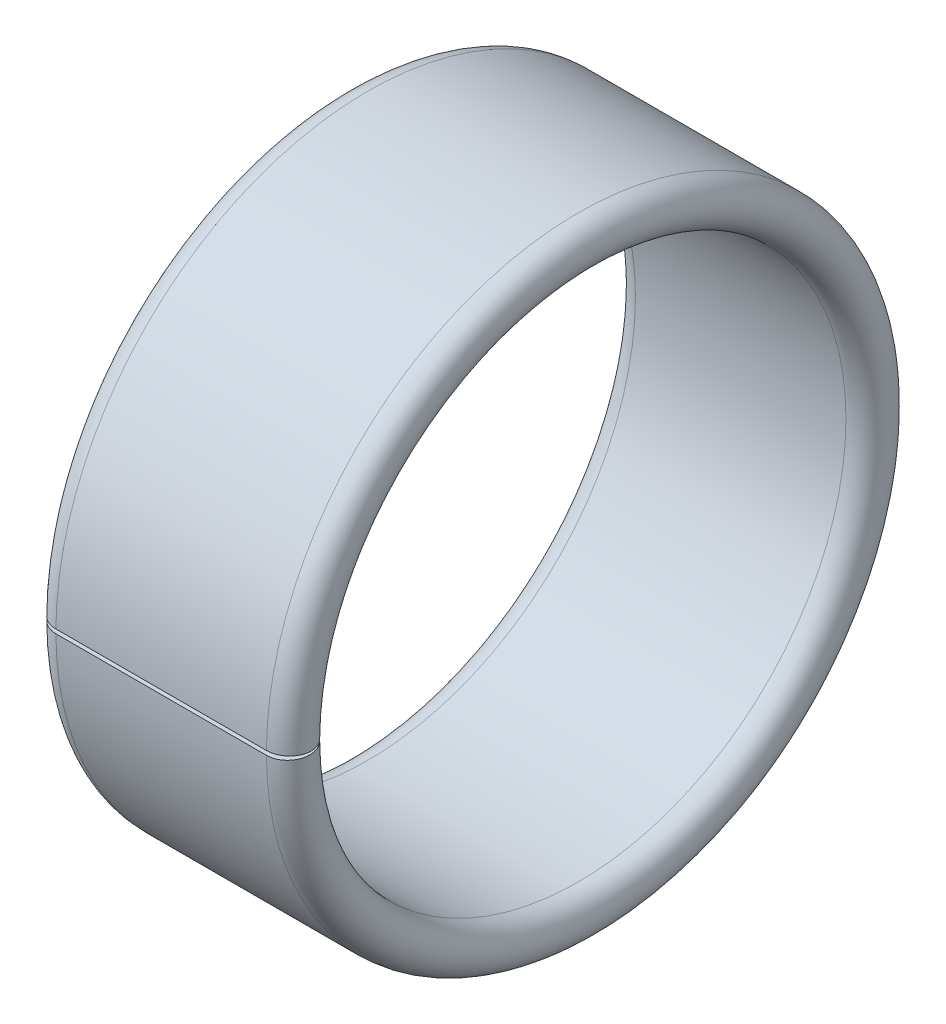
from build123d import *

# Parameters (mm, degrees)
CUT_EXTRUDE1_DEPTH = 4.9


with BuildPart() as part:
    # Sketch1 → Revolve1 (revolve)
    with BuildSketch(Plane.XY):
        with BuildLine():
            Line((0.425, 5.15), (4.475, 5.15))
            ThreePointArc((4.475, 5.15), (4.9, 5.575), (4.475, 6))
            Line((4.475, 6), (0.425, 6))
            ThreePointArc((0.425, 6), (0, 5.575), (0.425, 5.15))
        make_face()
    revolve(axis=Axis((4.9, 0, 0), (-1, 0, 0)))

    # Sketch2 → Cut-Extrude1 (cut)
    with BuildSketch(Plane(origin=(0, 0, 0), x_dir=(0, 0, -1), z_dir=(1, 0, 0))):
        with BuildLine():
            Line((-6.999602585, -0.074589885), (-4.863627758, 0))
            Line((-4.863627758, 0), (-6.999602585, 0.074589885))
            ThreePointArc((-6.999602585, 0.074589885), (-7, 0), (-6.999602585, -0.074589885))
        make_face()
    extrude(amount=CUT_EXTRUDE1_DEPTH, mode=Mode.SUBTRACT)


solid = part.part
